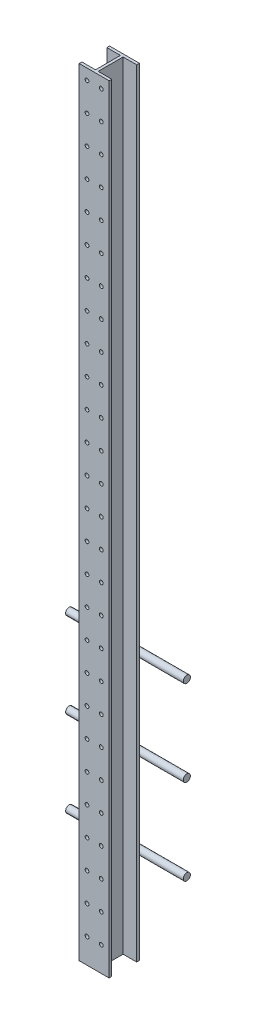
from build123d import *

# Parameters (mm, degrees)
BOSS_EXTRUDE1_DEPTH         = 2768.6
F_1_2_CLEARANCE_HOLE1_D     = 13.49248
F_1_2_CLEARANCE_HOLE1_DEPTH = 9.525
LPATTERN1_COUNT             = 27
LPATTERN1_PITCH             = 101.6
SKETCH4_R                   = 12.7
BOSS_EXTRUDE2_DEPTH         = 209.55
LPATTERN2_COUNT             = 3
LPATTERN2_PITCH             = 304.8


with BuildPart() as part:
    # Sketch1 → Boss-Extrude1 (new body)
    with BuildSketch(Plane(origin=(0, 0, 0), x_dir=(1, 0, 0), z_dir=(0, 1, 0))):
        Polygon((-4.7625, 9.525), (-4.7625, 98.425), (-53.213, 98.425), (-53.213, 107.95), (53.213, 107.95), (53.213, 98.425), (4.7625, 98.425), (4.7625, 9.525), (53.213, 9.525), (53.213, 0), (-53.213, 0), (-53.213, 9.525), align=None)
    extrude(amount=BOSS_EXTRUDE1_DEPTH)

    # 1/2 Clearance Hole1
    with Locations(Plane.XY):
        with Locations((25.4, 88.9), (-25.4, 88.9)):
            f_1_2_clearance_hole1 = Hole(F_1_2_CLEARANCE_HOLE1_D / 2, depth=F_1_2_CLEARANCE_HOLE1_DEPTH)

    # LPattern1: 1/2 Clearance Hole1 ×27
    with Locations(*[(0, i * LPATTERN1_PITCH, 0) for i in range(1, LPATTERN1_COUNT)]):
        add(f_1_2_clearance_hole1, mode=Mode.SUBTRACT)


with BuildPart() as body_2:
    # Sketch4 → Boss-Extrude2 (new body, symmetric)
    with BuildSketch(Plane(origin=(0, 0, 0), x_dir=(0, 0, -1), z_dir=(1, 0, 0))):
        with Locations((120.65, 330.2)):
            Circle(SKETCH4_R)
    boss_extrude2 = extrude(amount=BOSS_EXTRUDE2_DEPTH, both=True)


with BuildPart() as lpattern2_1:
    # LPattern2: Boss-Extrude2 ×3
    with Locations(*[(0, i * LPATTERN2_PITCH, 0) for i in range(1, LPATTERN2_COUNT)]):
        add(boss_extrude2)


solid = Compound([part.part, body_2.part, lpattern2_1.part])
